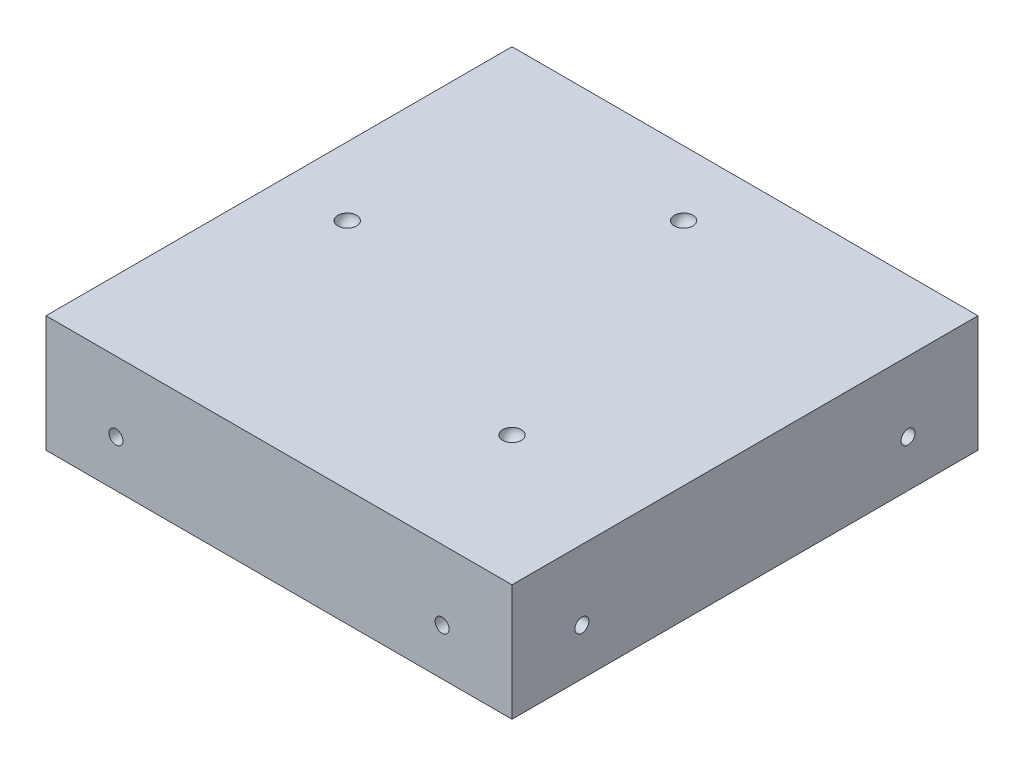
from build123d import *

# Parameters (mm, degrees)
SKETCH1_W           = 100
SKETCH1_H           = 100
BOSS_EXTRUDE1_DEPTH = 25
SKETCH5_R           = 1.5
CUT_EXTRUDE1_DEPTH  = 5
SKETCH6_R           = 1.5
CUT_EXTRUDE2_DEPTH  = 5
SKETCH7_R           = 1.5
CUT_EXTRUDE3_DEPTH  = 5
SKETCH8_R           = 1.5
CUT_EXTRUDE4_DEPTH  = 5


with BuildPart() as part:
    # Sketch1 → Boss-Extrude1 (new body)
    with BuildSketch(Plane(origin=(0, 0, 0), x_dir=(1, 0, 0), z_dir=(0, 1, 0))):
        Rectangle(SKETCH1_W, SKETCH1_H)
    extrude(amount=BOSS_EXTRUDE1_DEPTH)

    # Sketch2 → Cut-Revolve7 (revolve, cut)
    with BuildSketch(Plane(origin=(0, 25, 0), x_dir=(1, 0, 0), z_dir=(0, 1, 0))):
        with BuildLine():
            Line((-36.769552622, 1.414213562), (-33.941125497, -1.414213562))
            ThreePointArc((-33.941125497, -1.414213562), (-33.941125497, 1.414213562), (-36.769552622, 1.414213562))
        make_face()
    revolve(axis=Axis((-36.769552622, 25, -1.414213562), (0.707106781, 0, 0.707106781)), mode=Mode.SUBTRACT)

    # Sketch3 → Cut-Revolve8 (revolve, cut)
    with BuildSketch(Plane(origin=(0, 25, 0), x_dir=(1, 0, 0), z_dir=(0, 1, 0))):
        with BuildLine():
            Line((2.147947634, 34.674859569), (-0.680479491, 37.503286693))
            ThreePointArc((-0.680479491, 37.503286693), (2.147947634, 37.503286693), (2.147947634, 34.674859569))
        make_face()
    revolve(axis=Axis((2.147947634, 25, -34.674859569), (-0.707106781, 0, -0.707106781)), mode=Mode.SUBTRACT)

    # Sketch4 → Cut-Revolve9 (revolve, cut)
    with BuildSketch(Plane(origin=(0, 25, 0), x_dir=(1, 0, 0), z_dir=(0, 1, 0))):
        with BuildLine():
            Line((23.582045131, -23.582045131), (20.753618006, -20.753618006))
            ThreePointArc((20.753618006, -20.753618006), (23.582045131, -20.753618006), (23.582045131, -23.582045131))
        make_face()
    revolve(axis=Axis((-50, 25, -50), (0.707106781, 0, 0.707106781)), mode=Mode.SUBTRACT)

    # Sketch5 → Cut-Extrude1 (cut)
    with BuildSketch(Plane.XY.offset(50)):
        with Locations((-35, 10)):
            Circle(SKETCH5_R)
        with Locations((35, 10)):
            Circle(SKETCH5_R)
    extrude(amount=-CUT_EXTRUDE1_DEPTH, mode=Mode.SUBTRACT)

    # Sketch6 → Cut-Extrude2 (cut)
    with BuildSketch(Plane(origin=(50, 0, 0), x_dir=(0, 0, -1), z_dir=(1, 0, 0))):
        with Locations((-35, 10)):
            Circle(SKETCH6_R)
        with Locations((35, 10)):
            Circle(SKETCH6_R)
    extrude(amount=-CUT_EXTRUDE2_DEPTH, mode=Mode.SUBTRACT)

    # Sketch7 → Cut-Extrude3 (cut)
    with BuildSketch(Plane(origin=(0, 0, -50), x_dir=(-1, 0, 0), z_dir=(0, 0, -1))):
        with Locations(Location((-35, 10, 0), (0, 0, 180))):  # turned: the seam where the file's is
            Circle(SKETCH7_R)
        with Locations(Location((35, 10, 0), (0, 0, 180))):  # turned: the seam where the file's is
            Circle(SKETCH7_R)
    extrude(amount=-CUT_EXTRUDE3_DEPTH, mode=Mode.SUBTRACT)

    # Sketch8 → Cut-Extrude4 (cut)
    with BuildSketch(Plane.ZY.offset(50)):
        with Locations(Location((-35, 10, 0), (0, 0, 180))):  # turned: the seam where the file's is
            Circle(SKETCH8_R)
        with Locations(Location((35, 10, 0), (0, 0, 180))):  # turned: the seam where the file's is
            Circle(SKETCH8_R)
    extrude(amount=-CUT_EXTRUDE4_DEPTH, mode=Mode.SUBTRACT)


solid = part.part
